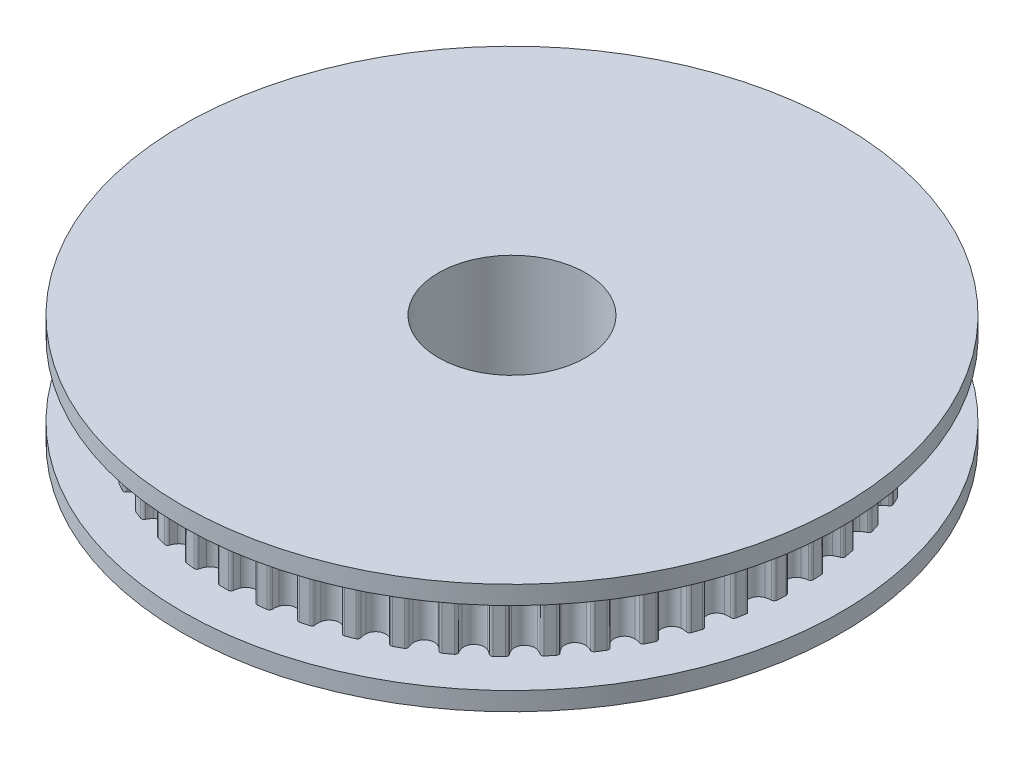
from build123d import *

# Parameters (mm, degrees)
SKETCH1_R               = 15.915494309
BOSS_EXTRUDE1_DEPTH     = 2
CUT_EXTRUDE1_DEPTH      = 3
CIRPATTERN1_COUNT       = 50
BOSS_EXTRUDE2_START     = 2
SKETCH3_R               = 17.915494309
BOSS_EXTRUDE2_DEPTH     = 1
BOSS_EXTRUDE3_START     = -2
SKETCH3_2_R             = 17.915494309
BOSS_EXTRUDE3_DEPTH     = 1
SKETCH4_R               = 4
CUT_EXTRUDE2_DEPTH      = 4
CUT_EXTRUDE2_DEPTH_BACK = 4


with BuildPart() as part:
    # Sketch1 → Boss-Extrude1 (new body, symmetric)
    with BuildSketch(Plane(origin=(0, 0, 0), x_dir=(1, 0, 0), z_dir=(0, 1, 0))):
        Circle(SKETCH1_R)
    extrude(amount=BOSS_EXTRUDE1_DEPTH, both=True)

    # Sketch2 → Cut-Extrude1 (cut, symmetric)
    with BuildSketch(Plane(origin=(0, 0, 0), x_dir=(1, 0, 0), z_dir=(0, 1, 0))):
        with BuildLine():
            Line((0, 15.661494309), (0, 15.915494309))
            ThreePointArc((0, 15.915494309), (0.999342156, 15.884088717), (1.994740366, 15.789995883))
            Line((1.994740366, 15.789995883), (1.962905724, 15.537998749))
            ThreePointArc((1.962905724, 15.537998749), (1.845415429, 15.552390359), (1.727819719, 15.565893582))
            ThreePointArc((1.727819719, 15.565893582), (1.623771116, 15.538644008), (1.564711807, 15.448751577))
            ThreePointArc((1.564711807, 15.448751577), (1.518780669, 15.297018757), (1.449447837, 15.154451312))
            ThreePointArc((1.449447837, 15.154451312), (0.936300475, 14.882069881), (0.461337878, 15.216617922))
            ThreePointArc((0.461337878, 15.216617922), (0.410420194, 15.366750888), (0.383868403, 15.523043947))
            ThreePointArc((0.383868403, 15.523043947), (0.336541303, 15.619629643), (0.236728432, 15.659705094))
            ThreePointArc((0.236728432, 15.659705094), (0.118367597, 15.661046999), (0, 15.661494309))
        make_face()
    cut_extrude1 = extrude(amount=CUT_EXTRUDE1_DEPTH, both=True, mode=Mode.SUBTRACT)

    # CirPattern1: Cut-Extrude1 ×50 about axis
    cirpattern1_axis = Axis((0, 0, 0), (0, 1, 0))
    for i in range(1, CIRPATTERN1_COUNT):
        add(cut_extrude1.rotate(cirpattern1_axis, i * 360 / CIRPATTERN1_COUNT), mode=Mode.SUBTRACT)

    # Sketch3 → Boss-Extrude2 (add)
    with BuildSketch(Plane(origin=(0, 0, 0), x_dir=(1, 0, 0), z_dir=(0, 1, 0)).offset(BOSS_EXTRUDE2_START)):
        Circle(SKETCH3_R)
    extrude(amount=BOSS_EXTRUDE2_DEPTH)

    # Sketch3_2 → Boss-Extrude3 (add)
    with BuildSketch(Plane(origin=(0, 0, 0), x_dir=(1, 0, 0), z_dir=(0, 1, 0)).offset(BOSS_EXTRUDE3_START)):
        Circle(SKETCH3_2_R)
    extrude(amount=-BOSS_EXTRUDE3_DEPTH)

    # Sketch4 → Cut-Extrude2 (cut, two sides)
    with BuildSketch(Plane(origin=(0, 0, 0), x_dir=(1, 0, 0), z_dir=(0, 1, 0))) as cut_extrude2_sk:
        Circle(SKETCH4_R)
    extrude(amount=CUT_EXTRUDE2_DEPTH, mode=Mode.SUBTRACT)
    extrude(cut_extrude2_sk.sketch, amount=-CUT_EXTRUDE2_DEPTH_BACK, mode=Mode.SUBTRACT)


solid = part.part
